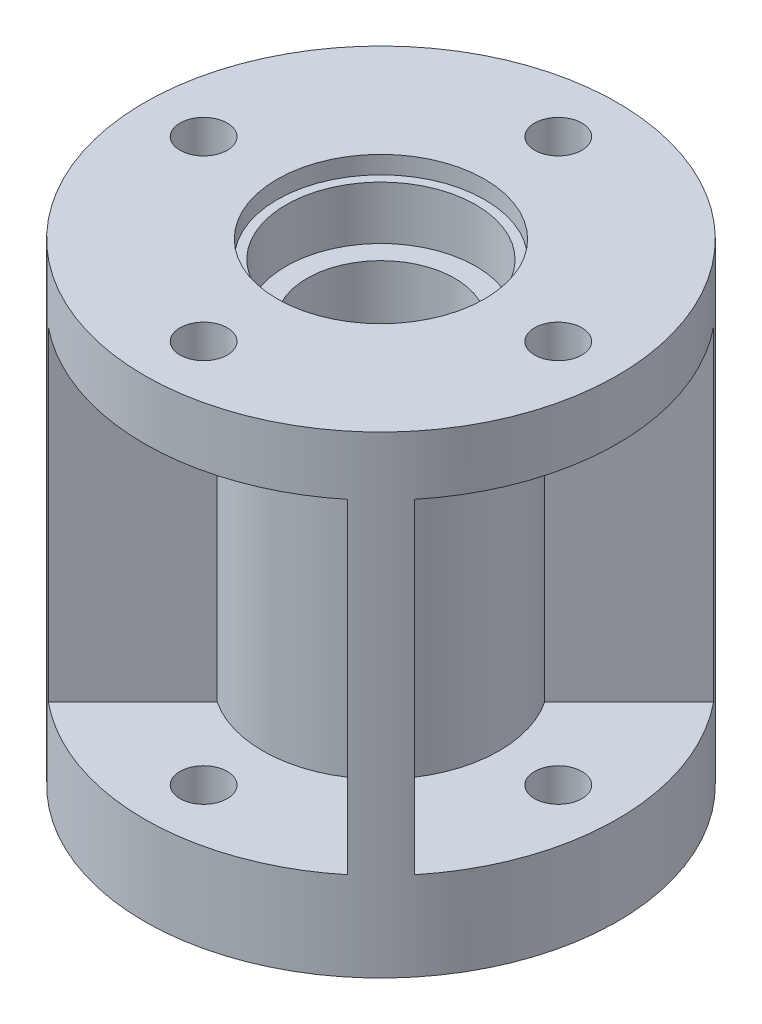
from build123d import *

# Parameters (mm, degrees)
SKETCH1_R           = 40
SKETCH1_R_2         = 12.5
BOSS_EXTRUDE1_DEPTH = 15
SKETCH3_R           = 20
SKETCH3_R_2         = 12.5
BOSS_EXTRUDE2_DEPTH = 53
SKETCH4_R           = 20
SKETCH4_R_2         = 16.05
BOSS_EXTRUDE3_DEPTH = 12
BOSS_EXTRUDE4_DEPTH = 65
SKETCH6_R           = 17.55
CUT_EXTRUDE2_DEPTH  = 3
SKETCH7_R           = 40
SKETCH7_R_2         = 20
BOSS_EXTRUDE5_DEPTH = 10
SKETCH2_R           = 4
CUT_EXTRUDE1_DEPTH  = 80


with BuildPart() as part:
    # Sketch1 → Boss-Extrude1 (new body)
    with BuildSketch(Plane(origin=(0, 0, 0), x_dir=(1, 0, 0), z_dir=(0, 1, 0))):
        Circle(SKETCH1_R)
        Circle(SKETCH1_R_2, mode=Mode.SUBTRACT)
    extrude(amount=BOSS_EXTRUDE1_DEPTH)

    # Sketch3 → Boss-Extrude2 (add)
    with BuildSketch(Plane(origin=(0, 15, 0), x_dir=(1, 0, 0), z_dir=(0, 1, 0))):
        Circle(SKETCH3_R)
        Circle(SKETCH3_R_2, mode=Mode.SUBTRACT)
    extrude(amount=BOSS_EXTRUDE2_DEPTH)

    # Sketch4 → Boss-Extrude3 (add)
    with BuildSketch(Plane(origin=(0, 68, 0), x_dir=(1, 0, 0), z_dir=(0, 1, 0))):
        Circle(SKETCH4_R)
        Circle(SKETCH4_R_2, mode=Mode.SUBTRACT)
    extrude(amount=BOSS_EXTRUDE3_DEPTH)

    # Sketch5 → Boss-Extrude4 (add)
    with BuildSketch(Plane(origin=(0, 15, 0), x_dir=(1, 0, 0), z_dir=(0, 1, 0))):
        with BuildLine():
            Line((-16.684833585, -11.027979336), (-30.970921684, -25.314067434))
            ThreePointArc((-30.970921684, -25.314067434), (-28.284271247, -28.284271247), (-25.314067434, -30.970921684))
            Line((-25.314067434, -30.970921684), (-11.027979336, -16.684833585))
            ThreePointArc((-11.027979336, -16.684833585), (-14.142135624, -14.142135624), (-16.684833585, -11.027979336))
        make_face()
        with BuildLine():
            Line((-16.684833585, 11.027979336), (-30.970921684, 25.314067434))
            ThreePointArc((-30.970921684, 25.314067434), (-28.284271247, 28.284271247), (-25.314067434, 30.970921684))
            Line((-25.314067434, 30.970921684), (-11.027979336, 16.684833585))
            ThreePointArc((-11.027979336, 16.684833585), (-14.142135624, 14.142135624), (-16.684833585, 11.027979336))
        make_face()
        with BuildLine():
            Line((11.027979336, 16.684833585), (25.314067434, 30.970921684))
            ThreePointArc((25.314067434, 30.970921684), (28.284271247, 28.284271247), (30.970921684, 25.314067434))
            Line((30.970921684, 25.314067434), (16.684833585, 11.027979336))
            ThreePointArc((16.684833585, 11.027979336), (14.142135624, 14.142135624), (11.027979336, 16.684833585))
        make_face()
        with BuildLine():
            Line((16.684833585, -11.027979336), (30.970921684, -25.314067434))
            ThreePointArc((30.970921684, -25.314067434), (28.284271247, -28.284271247), (25.314067434, -30.970921684))
            Line((25.314067434, -30.970921684), (11.027979336, -16.684833585))
            ThreePointArc((11.027979336, -16.684833585), (14.142135624, -14.142135624), (16.684833585, -11.027979336))
        make_face()
    extrude(amount=BOSS_EXTRUDE4_DEPTH)

    # Sketch6 → Cut-Extrude2 (cut)
    with BuildSketch(Plane(origin=(0, 80, 0), x_dir=(1, 0, 0), z_dir=(0, 1, 0))):
        Circle(SKETCH6_R)
    extrude(amount=-CUT_EXTRUDE2_DEPTH, mode=Mode.SUBTRACT)

    # Sketch7 → Boss-Extrude5 (add)
    with BuildSketch(Plane(origin=(0, 80, 0), x_dir=(1, 0, 0), z_dir=(0, 1, 0))):
        Circle(SKETCH7_R)
        Circle(SKETCH7_R_2, mode=Mode.SUBTRACT)
    extrude(amount=-BOSS_EXTRUDE5_DEPTH)

    # Sketch2 → Cut-Extrude1 (cut)
    with BuildSketch(Plane(origin=(0, 0, 0), x_dir=(1, 0, 0), z_dir=(0, 1, 0))):
        with Locations((0, 30)):
            Circle(SKETCH2_R)
        with Locations((30, 0)):
            Circle(SKETCH2_R)
        with Locations((0, -30)):
            Circle(SKETCH2_R)
        with Locations((-30, 0)):
            Circle(SKETCH2_R)
    extrude(amount=CUT_EXTRUDE1_DEPTH, mode=Mode.SUBTRACT)


solid = part.part
